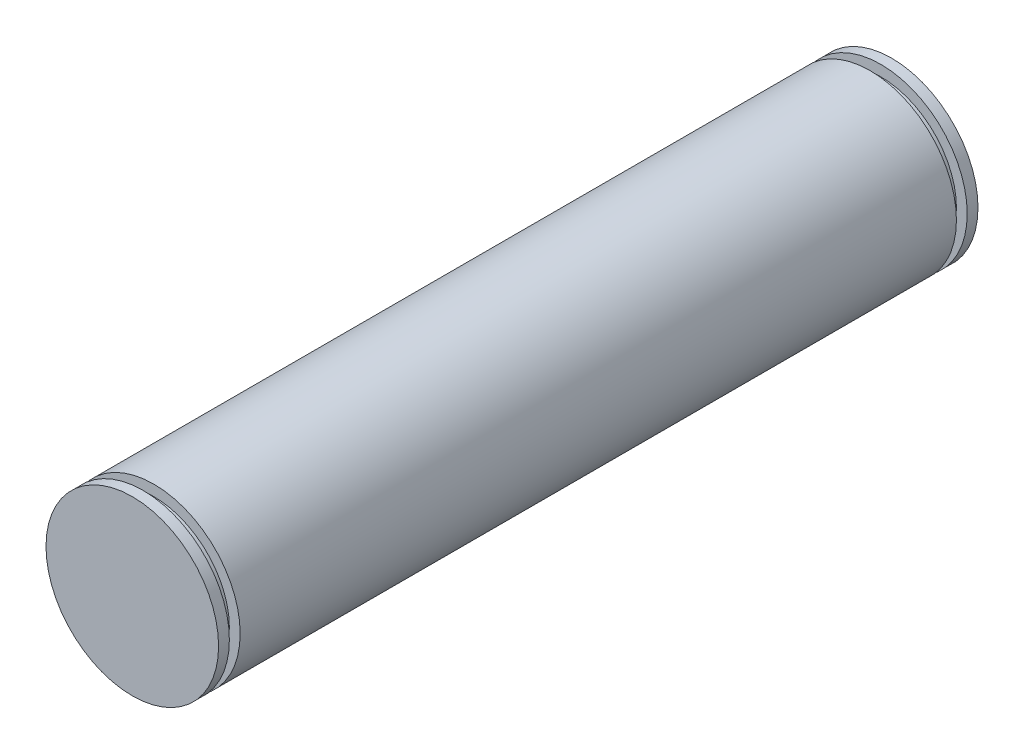
from build123d import *


with BuildPart() as part:
    # Sketch1 → Revolve1 (revolve)
    with BuildSketch(Plane(origin=(0, 0, 0), x_dir=(1, 0, 0), z_dir=(0, 1, 0))):
        Polygon((0, 0), (12.7, 0), (12.7, 1.5875), (11.1125, 1.5875), (11.1125, 3.175), (12.7, 3.175), (12.7, 108.585), (11.1125, 108.585), (11.1125, 110.1725), (12.7, 110.1725), (12.7, 111.76), (0, 111.76), align=None)
    revolve(axis=Axis((0, 0, 0), (0, 0, -1)))


solid = part.part
